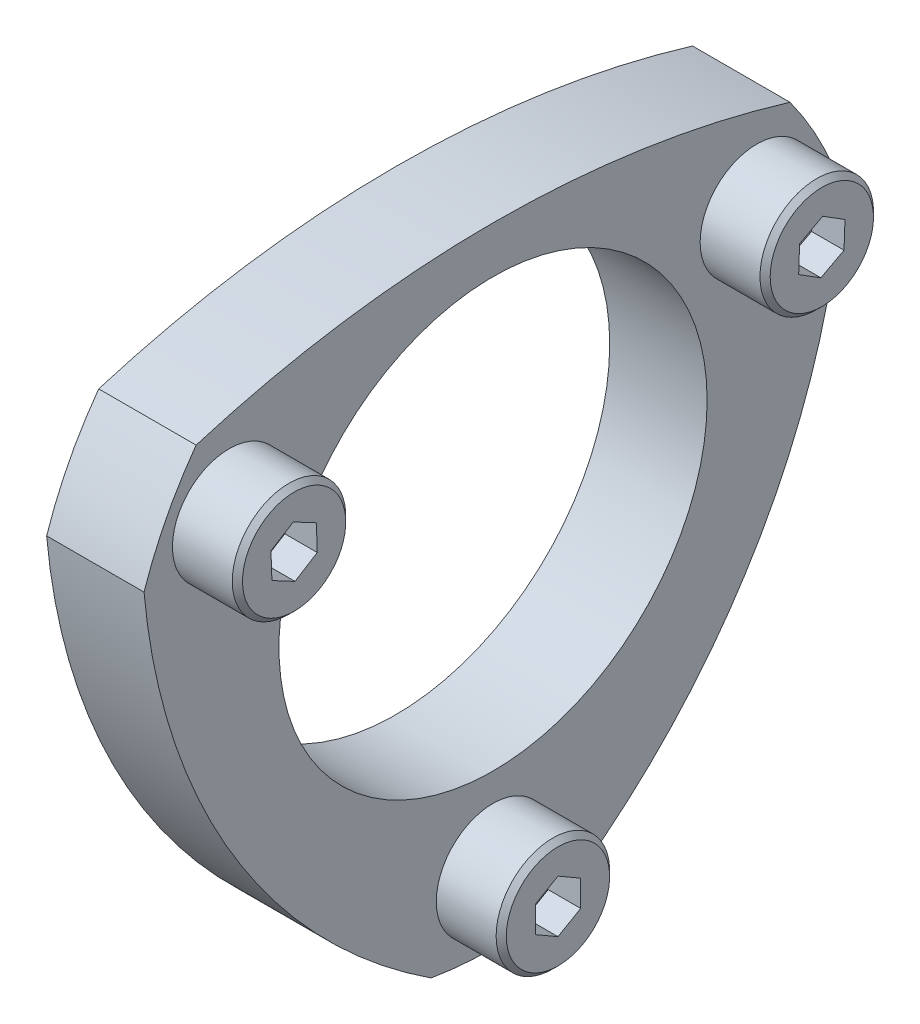
from build123d import *

# Parameters (mm, degrees)
SKETCH1_R           = 10.63625
BOSS_EXTRUDE1_DEPTH = 4.8387
HOLE1_D             = 3.7592
HOLE2_D             = 3.7592
HOLE3_D             = 3.7592
CUT_EXTRUDE1_DEPTH  = 1.6129
CUT_EXTRUDE2_DEPTH  = 1.6129
CUT_EXTRUDE3_DEPTH  = 1.6129


with BuildPart() as part:
    # Sketch1 → Boss-Extrude1 (new body)
    with BuildSketch(Plane(origin=(0, 0, 0), x_dir=(0, 0, -1), z_dir=(1, 0, 0))):
        with BuildLine():
            ThreePointArc((-17.339461313, 5.732856195), (-12.932597366, -7.770688459), (-3.078572423, -18.001248584))
            ThreePointArc((-3.078572423, -18.001248584), (0, -18.2626), (3.078572423, -18.001248584))
            ThreePointArc((3.078572423, -18.001248584), (12.932597366, -7.770688459), (17.339461313, 5.732856195))
            ThreePointArc((17.339461313, 5.732856195), (16.242165379, 8.349528284), (14.752793477, 10.764647852))
            ThreePointArc((14.752793477, 10.764647852), (0, 12.954), (-14.752793477, 10.764647852))
            ThreePointArc((-14.752793477, 10.764647852), (-16.242165379, 8.349528284), (-17.339461313, 5.732856195))
        make_face()
        Circle(SKETCH1_R, mode=Mode.SUBTRACT)
    extrude(amount=BOSS_EXTRUDE1_DEPTH)

    # Hole1 (through all)
    with Locations(Plane(origin=(4.8387, 0, 0), x_dir=(0, 0, -1), z_dir=(1, 0, 0))):
        with Locations((-13.108504848, 6.969915663)):
            Hole(HOLE1_D / 2)

    # Sketch4 → Revolve1 (revolve)
    with BuildSketch(Plane(origin=(0, 0, 0), x_dir=(-1, 0, 0), z_dir=(0, -0.882947592858928, 0.469471562785889))):
        Polygon((-4.8387, -14.8463), (-4.8387, -17.6657), (-7.8105, -17.6657), (-8.0645, -17.4117), (-8.0645, -14.8463), align=None)
    revolve(axis=Axis((8.0645, 6.969915663, 13.108504848), (-1, 0, 0)))

    # Hole2 (through all)
    with Locations(Plane(origin=(4.8387, 0, 0), x_dir=(0, 0, -1), z_dir=(1, 0, 0))):
        with Locations((13.108504848, 6.969915663)):
            Hole(HOLE2_D / 2)

    # Sketch7 → Revolve2 (revolve)
    with BuildSketch(Plane(origin=(0, 0, 0), x_dir=(1, 0, 0), z_dir=(0, 0.882947592858928, 0.469471562785889))):
        Polygon((4.8387, 14.8463), (4.8387, 17.6657), (7.8105, 17.6657), (8.0645, 17.4117), (8.0645, 14.8463), align=None)
    revolve(axis=Axis((8.0645, 6.969915663, -13.108504848), (-1, 0, 0)))

    # Hole3 (through all)
    with Locations(Plane(origin=(4.8387, 0, 0), x_dir=(0, 0, -1), z_dir=(1, 0, 0))):
        with Locations((0, -14.8463)):
            Hole(HOLE3_D / 2)

    # Sketch10 → Revolve3 (revolve)
    with BuildSketch(Plane.XY):
        Polygon((4.8387, -14.8463), (4.8387, -12.0269), (7.8105, -12.0269), (8.0645, -12.2809), (8.0645, -14.8463), align=None)
    revolve(axis=Axis((8.0645, -14.8463, 0), (-1, 0, 0)))

    # Sketch11 → Cut-Extrude1 (cut)
    with BuildSketch(Plane(origin=(8.0645, 0, 0), x_dir=(0, 0, -1), z_dir=(1, 0, 0))):
        Polygon((-1.12776, -14.19518746), (-1.12776, -15.49741254), (0, -16.148525079), (1.12776, -15.49741254), (1.12776, -14.19518746), (0, -13.544074921), align=None)
    extrude(amount=-CUT_EXTRUDE1_DEPTH, mode=Mode.SUBTRACT)

    # Sketch12 → Cut-Extrude2 (cut)
    with BuildSketch(Plane(origin=(8.0645, 0, 0), x_dir=(0, 0, -1), z_dir=(1, 0, 0))):
        Polygon((11.958708349, 6.35855802), (13.063057848, 5.668483864), (14.212854347, 6.279841507), (14.258301347, 7.581273306), (13.153951848, 8.271347461), (12.004155349, 7.659989818), align=None)
    extrude(amount=-CUT_EXTRUDE2_DEPTH, mode=Mode.SUBTRACT)

    # Sketch13 → Cut-Extrude3 (cut)
    with BuildSketch(Plane(origin=(8.0645, 0, 0), x_dir=(0, 0, -1), z_dir=(1, 0, 0))):
        Polygon((-14.258301347, 7.581273306), (-14.212854347, 6.279841507), (-13.063057848, 5.668483864), (-11.958708349, 6.35855802), (-12.004155349, 7.659989818), (-13.153951848, 8.271347461), align=None)
    extrude(amount=-CUT_EXTRUDE3_DEPTH, mode=Mode.SUBTRACT)


solid = part.part
